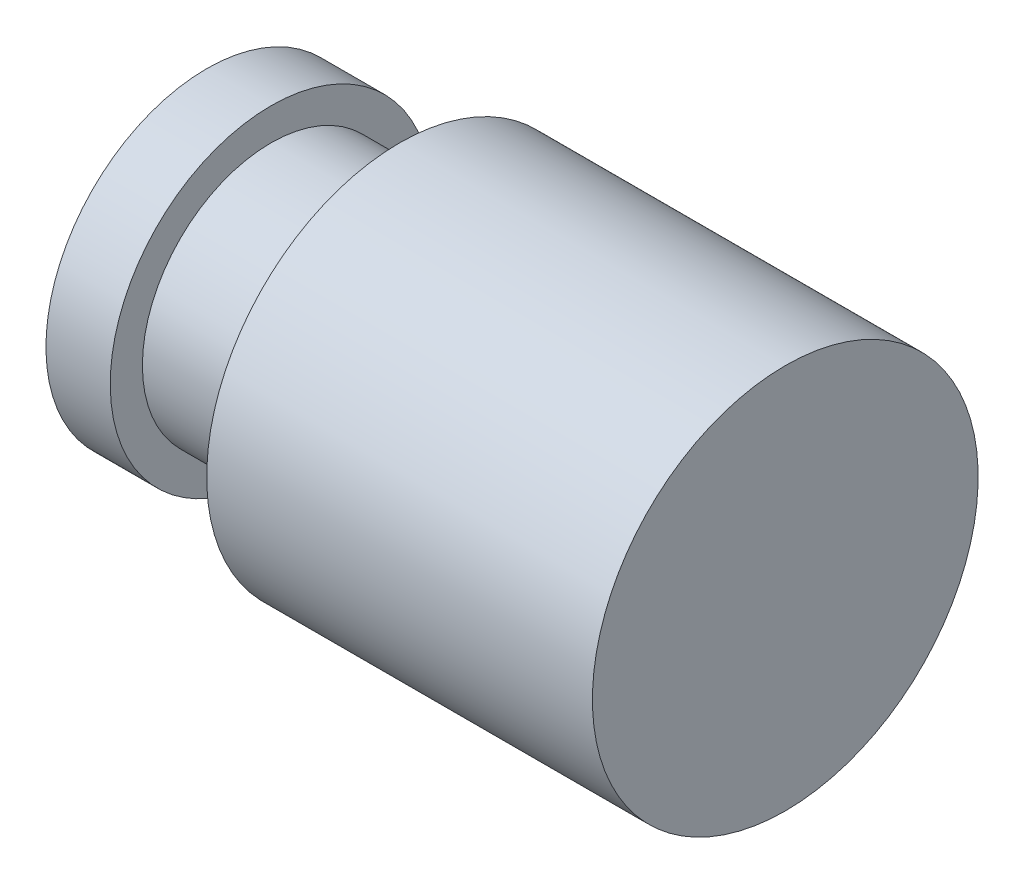
from build123d import *


with BuildPart() as part:
    # Esquisse1 → Révolution1 (revolve)
    with BuildSketch(Plane.XY):
        Polygon((0, 0), (0, 2.5), (1, 2.5), (1, 2), (3, 2), (3, 3), (9, 3), (9, 2), (9, 0), align=None)
    revolve(axis=Axis((9, 0, 0), (-1, 0, 0)))


solid = part.part
